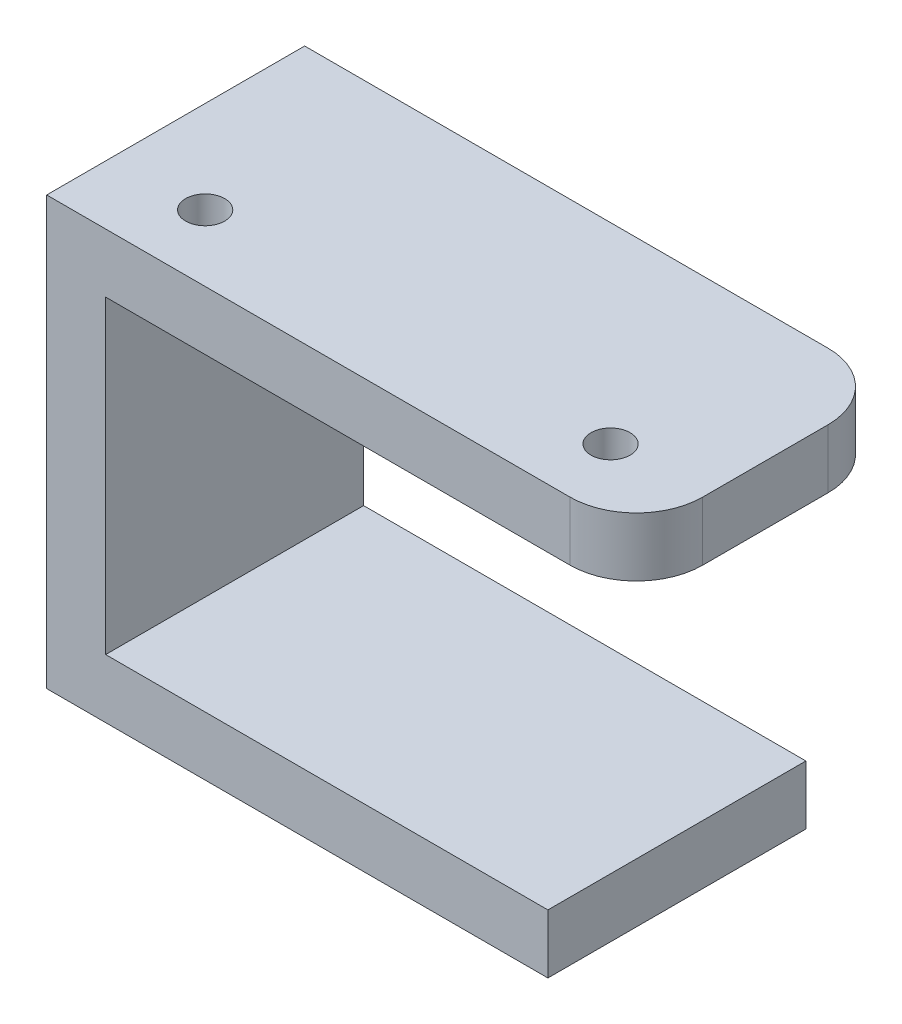
from build123d import *

# Parameters (mm, degrees)
SKETCH1_R           = 2.65
BOSS_EXTRUDE1_DEPTH = 8
SKETCH2_W           = 8
SKETCH2_H           = 35
BOSS_EXTRUDE2_DEPTH = 50
SKETCH3_W           = 35
SKETCH3_H           = 8
BOSS_EXTRUDE3_DEPTH = 60


with BuildPart() as part:
    # Sketch1 → Boss-Extrude1 (new body)
    with BuildSketch(Plane(origin=(0, 0, 0), x_dir=(1, 0, 0), z_dir=(0, 1, 0))):
        with BuildLine():
            Line((0, 0), (71, 0))
            ThreePointArc((71, 0), (77.363961031, 2.636038969), (80, 9))
            Line((80, 9), (80, 26))
            ThreePointArc((80, 26), (77.363961031, 32.363961031), (71, 35))
            Line((71, 35), (0, 35))
            Line((0, 35), (0, 0))
        make_face()
        with Locations((12.5, 9)):
            Circle(SKETCH1_R, mode=Mode.SUBTRACT)
        with Locations((67.5, 9)):
            Circle(SKETCH1_R, mode=Mode.SUBTRACT)
    extrude(amount=BOSS_EXTRUDE1_DEPTH)

    # Sketch2 → Boss-Extrude2 (add)
    with BuildSketch(Plane.XZ):
        with Locations((4, -17.5)):
            Rectangle(SKETCH2_W, SKETCH2_H)
    extrude(amount=BOSS_EXTRUDE2_DEPTH)

    # Sketch3 → Boss-Extrude3 (add)
    with BuildSketch(Plane(origin=(8, 0, 0), x_dir=(0, 0, -1), z_dir=(1, 0, 0))):
        with Locations((17.5, -46)):
            Rectangle(SKETCH3_W, SKETCH3_H)
    extrude(amount=BOSS_EXTRUDE3_DEPTH)


solid = part.part
